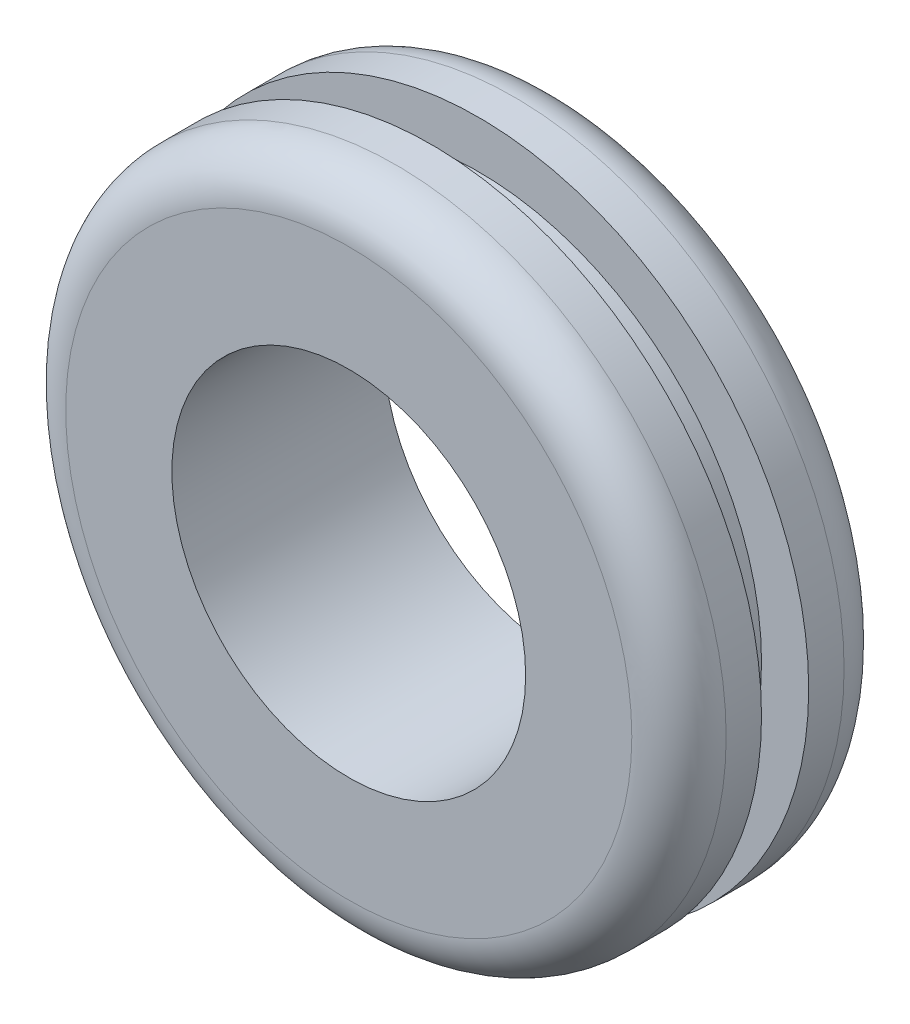
from build123d import *

# Parameters (mm, degrees)
ESQUISSE1_R             = 14
BOSS_EXTRU_1_DEPTH      = 4.5
CONG_1_R                = 2
ESQUISSE14_W            = 2
ESQUISSE14_H            = 2
ESQUISSE15_R            = 7.5
ENL_V_MAT_EXTRU_2_DEPTH = 10


with BuildPart() as part:
    # Esquisse1 → Boss.-Extru.1 (new body, symmetric)
    with BuildSketch(Plane.XY):
        Circle(ESQUISSE1_R)
    extrude(amount=BOSS_EXTRU_1_DEPTH, both=True)

    # Congé1
    cong_1_edges = [part.edges().sort_by_distance(p)[0] for p in [
        (-14, 0, -4.5),
        (-14, 0, 4.5),
    ]]
    fillet(cong_1_edges, radius=CONG_1_R)

    # Esquisse14 → Enlèvement de matière-Révolution2 (revolve, cut)
    with BuildSketch(Plane(origin=(0, 0, 0), x_dir=(0, 0, -1), z_dir=(1, 0, 0))):
        with Locations((0, 13)):
            Rectangle(ESQUISSE14_W, ESQUISSE14_H)
    revolve(axis=Axis((0, 0, 11.517879347), (0, 0, -1)), mode=Mode.SUBTRACT)

    # Esquisse15 → Enlèv. mat.-Extru.2 (cut, through all)
    with BuildSketch(Plane.XY.offset(4.5)):
        Circle(ESQUISSE15_R)
    extrude(amount=-ENL_V_MAT_EXTRU_2_DEPTH, mode=Mode.SUBTRACT)


solid = part.part
